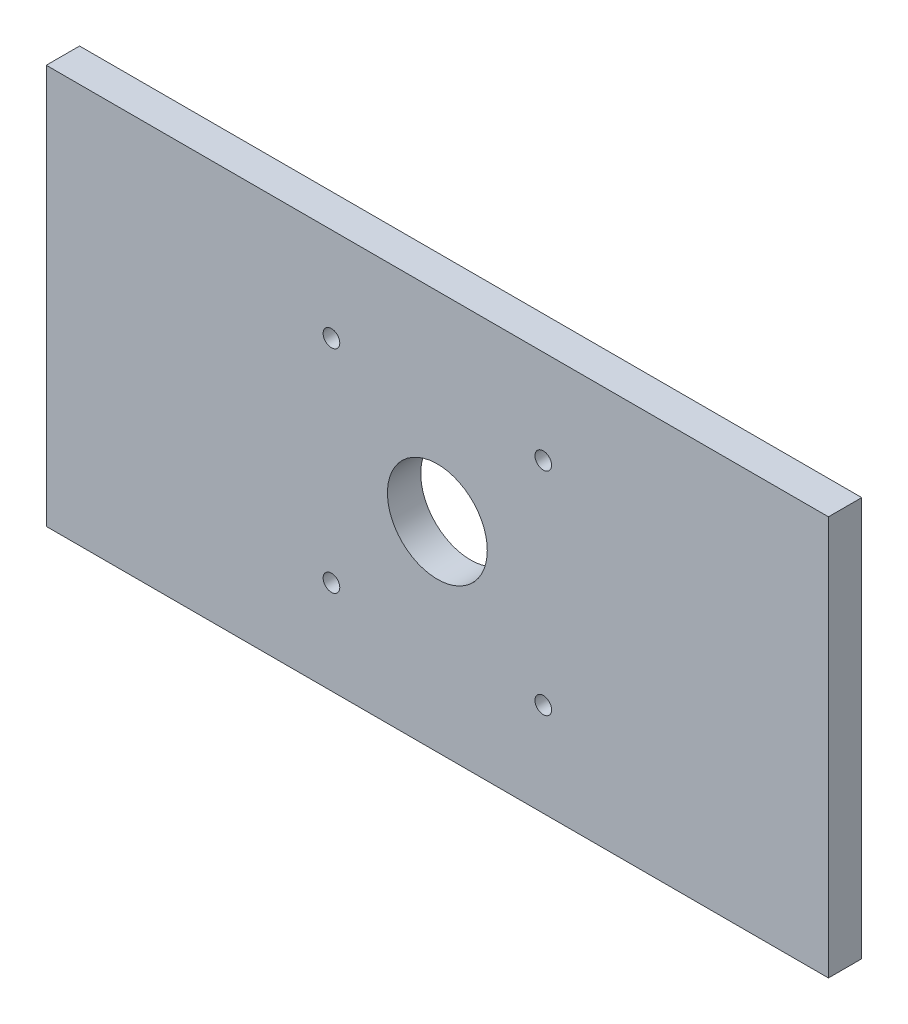
from build123d import *

# Parameters (mm, degrees)
SKETCH1_W           = 235
SKETCH1_H           = 120
BOSS_EXTRUDE1_DEPTH = 10
SKETCH2_R           = 15
CUT_EXTRUDE1_DEPTH  = 10
SKETCH3_R           = 2.5
CUT_EXTRUDE2_DEPTH  = 10


with BuildPart() as part:
    # Sketch1 → Boss-Extrude1 (new body)
    with BuildSketch(Plane.XY):
        Rectangle(SKETCH1_W, SKETCH1_H)
    extrude(amount=BOSS_EXTRUDE1_DEPTH)

    # Sketch2 → Cut-Extrude1 (cut)
    with BuildSketch(Plane.XY.offset(10)):
        Circle(SKETCH2_R)
    extrude(amount=-CUT_EXTRUDE1_DEPTH, mode=Mode.SUBTRACT)

    # Sketch3 → Cut-Extrude2 (cut)
    with BuildSketch(Plane.XY.offset(10)):
        with Locations((31.819805153, 31.819805153)):
            Circle(SKETCH3_R)
        with Locations((31.819805153, -31.819805153)):
            Circle(SKETCH3_R)
        with Locations((-31.819805153, -31.819805153)):
            Circle(SKETCH3_R)
        with Locations((-31.819805153, 31.819805153)):
            Circle(SKETCH3_R)
    extrude(amount=-CUT_EXTRUDE2_DEPTH, mode=Mode.SUBTRACT)


solid = part.part
